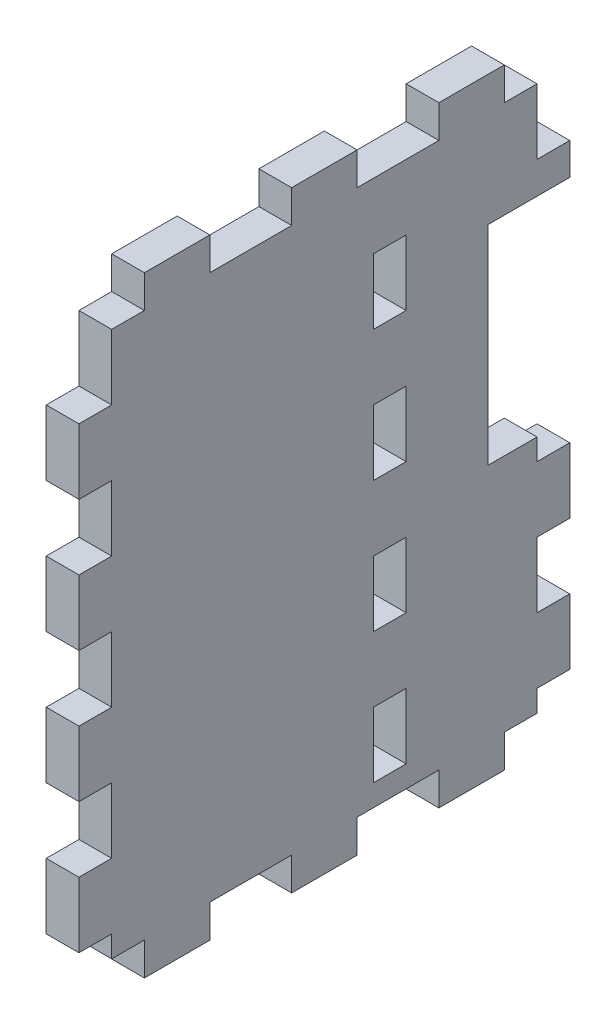
from build123d import *

# Parameters (mm, degrees)
SKETCH5_W           = 6.35
SKETCH5_H           = 118.538155393
BOSS_EXTRUDE1_DEPTH = 95.25
SKETCH7_W           = 6.35
SKETCH7_H           = 12.7
CUT_EXTRUDE1_DEPTH  = 7.35
LPATTERN1_COUNT     = 5
LPATTERN1_PITCH     = 25.4
SKETCH8_W           = 6.35
SKETCH8_H           = 12.7
CUT_EXTRUDE2_DEPTH  = 7.35
LPATTERN2_COUNT     = 5
LPATTERN2_PITCH     = 25.4
CUT_EXTRUDE3_DEPTH  = 15.875
SKETCH10_W          = 12.7
SKETCH10_H          = 6.35
SKETCH10_W_2        = 15.875
CUT_EXTRUDE4_DEPTH  = 7.35
SKETCH11_W          = 6.35
SKETCH11_H          = 6.3881
SKETCH11_W_2        = 15.875
CUT_EXTRUDE5_DEPTH  = 7.35
SKETCH13_W          = 6.35
SKETCH13_H          = 2.311210988
SKETCH13_H_2        = 2.900340521
CUT_EXTRUDE6_DEPTH  = 15.875


with BuildPart() as part:
    # Sketch5 → Boss-Extrude1 (new body)
    with BuildSketch(Plane.XY):
        with Locations((60.833541785, 251.880922304)):
            Rectangle(SKETCH5_W, SKETCH5_H)
    extrude(amount=BOSS_EXTRUDE1_DEPTH)

    # Sketch7 → Cut-Extrude1 (cut, through all)
    with BuildSketch(Plane(origin=(64.008541785, 0, 0), x_dir=(0, 0, -1), z_dir=(1, 0, 0))):
        with Locations((-92.075, 298.45)):
            Rectangle(SKETCH7_W, SKETCH7_H)
        with Locations((-3.175, 298.45)):
            Rectangle(SKETCH7_W, SKETCH7_H)
    cut_extrude1 = extrude(amount=-CUT_EXTRUDE1_DEPTH, mode=Mode.SUBTRACT)

    # LPattern1: Cut-Extrude1 ×5
    with Locations(*[(0, -i * LPATTERN1_PITCH, 0) for i in range(1, LPATTERN1_COUNT)]):
        add(cut_extrude1, mode=Mode.SUBTRACT)

    # Sketch8 → Cut-Extrude2 (cut, through all)
    with BuildSketch(Plane(origin=(64.008541785, 0, 0), x_dir=(0, 0, -1), z_dir=(1, 0, 0))):
        with Locations((-34.925, 311.15)):
            Rectangle(SKETCH8_W, SKETCH8_H)
    cut_extrude2 = extrude(amount=-CUT_EXTRUDE2_DEPTH, mode=Mode.SUBTRACT)

    # LPattern2: Cut-Extrude2 ×5
    with Locations(*[(0, -i * LPATTERN2_PITCH, 0) for i in range(1, LPATTERN2_COUNT)]):
        add(cut_extrude2, mode=Mode.SUBTRACT)

    # Sketch9 → Cut-Extrude3 (cut)
    with BuildSketch(Plane(origin=(0, 0, 0), x_dir=(-1, 0, 0), z_dir=(0, 0, -1))):
        with BuildLine():
            Line((-42.140789022, 277.931008412), (-81.069773467, 292.1))
            Line((-81.069773467, 292.1), (-81.069773467, 237.646932857))
            Line((-81.069773467, 237.646932857), (-41.263032712, 255.828523916))
            ThreePointArc((-41.263032712, 255.828523916), (-34.286165861, 267.174267761), (-42.140789022, 277.931008412))
        make_face()
    extrude(amount=-CUT_EXTRUDE3_DEPTH, mode=Mode.SUBTRACT)

    # Sketch10 → Cut-Extrude4 (cut, through all)
    with BuildSketch(Plane(origin=(64.008541785, 0, 0), x_dir=(0, 0, -1), z_dir=(1, 0, 0))):
        with Locations((-88.9, 307.975)):
            Rectangle(SKETCH10_W, SKETCH10_H)
        with Locations((-61.9125, 307.975)):
            Rectangle(SKETCH10_W_2, SKETCH10_H)
        with Locations((-33.3375, 307.975)):
            Rectangle(SKETCH10_W_2, SKETCH10_H)
        with Locations((-6.35, 307.975)):
            Rectangle(SKETCH10_W, SKETCH10_H)
    extrude(amount=-CUT_EXTRUDE4_DEPTH, mode=Mode.SUBTRACT)

    # Sketch11 → Cut-Extrude5 (cut, through all)
    with BuildSketch(Plane(origin=(64.008541785, 0, 0), x_dir=(0, 0, -1), z_dir=(1, 0, 0))):
        with Locations((-85.725, 195.805894607)):
            Rectangle(SKETCH11_W, SKETCH11_H)
        with Locations((-61.9125, 195.805894607)):
            Rectangle(SKETCH11_W_2, SKETCH11_H)
        with Locations((-33.3375, 195.805894607)):
            Rectangle(SKETCH11_W_2, SKETCH11_H)
        with Locations((-9.525, 195.805894607)):
            Rectangle(SKETCH11_W, SKETCH11_H)
    extrude(amount=-CUT_EXTRUDE5_DEPTH, mode=Mode.SUBTRACT)

    # Sketch13 → Cut-Extrude6 (cut)
    with BuildSketch(Plane(origin=(0, 0, 0), x_dir=(-1, 0, 0), z_dir=(0, 0, -1))):
        with Locations((-60.833541785, 284.734614014)):
            Rectangle(SKETCH13_W, SKETCH13_H)
        with Locations((-60.833541785, 246.889761636)):
            Rectangle(SKETCH13_W, SKETCH13_H_2)
    extrude(amount=-CUT_EXTRUDE6_DEPTH, mode=Mode.SUBTRACT)


solid = part.part
